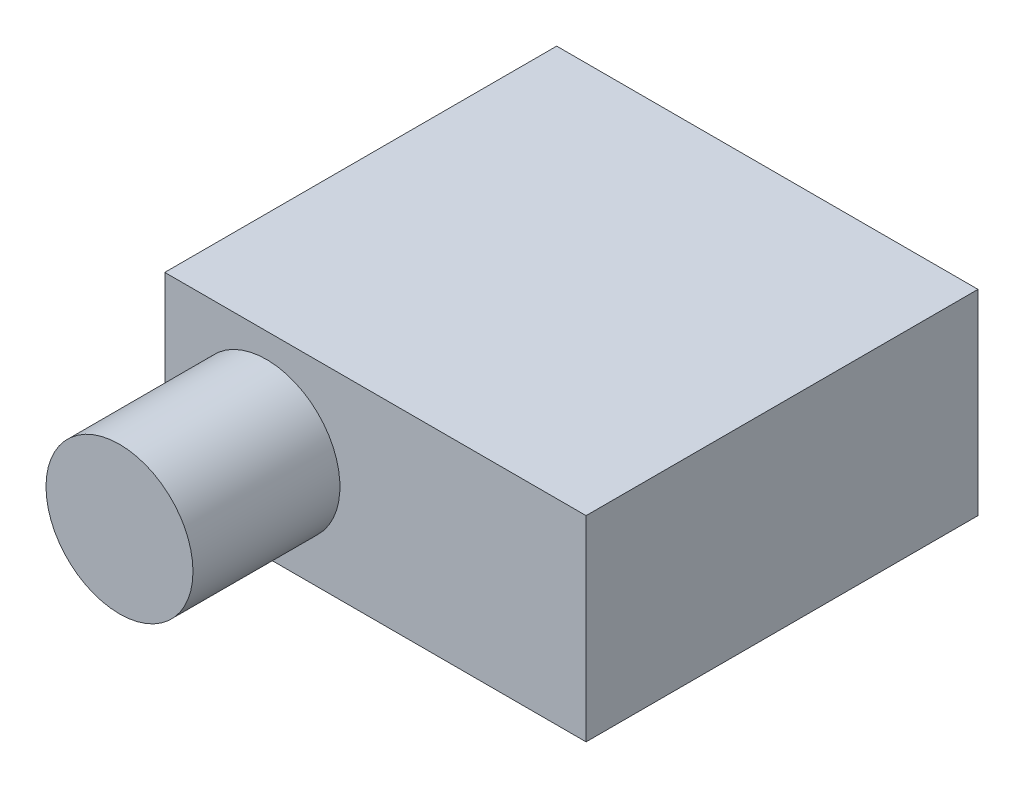
from build123d import *

# Parameters (mm, degrees)
SKETCH1_W           = 43
SKETCH1_H           = 20
BOSS_EXTRUDE1_DEPTH = 40
SKETCH2_R           = 7.5
BOSS_EXTRUDE2_DEPTH = 15


with BuildPart() as part:
    # Sketch1 → Boss-Extrude1 (new body)
    with BuildSketch(Plane.XY):
        Rectangle(SKETCH1_W, SKETCH1_H)
    extrude(amount=BOSS_EXTRUDE1_DEPTH)

    # Sketch2 → Boss-Extrude2 (add)
    with BuildSketch(Plane.XY.offset(40)):
        with Locations((-11.122255155, 0)):
            Circle(SKETCH2_R)
    extrude(amount=BOSS_EXTRUDE2_DEPTH)


solid = part.part
